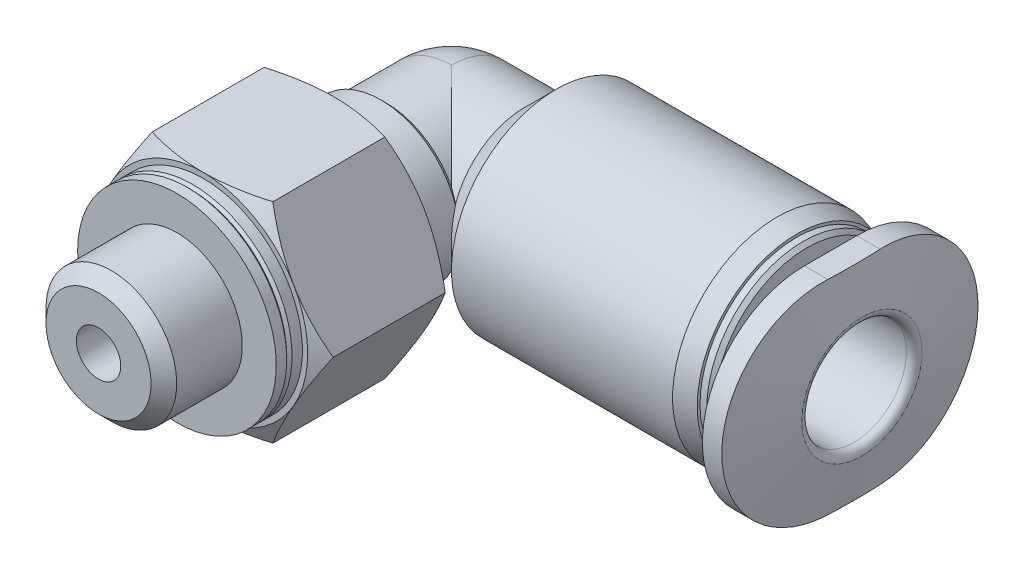
from build123d import *

# Parameters (mm, degrees)
CUT_EXTRUDE1_DEPTH = 1.2
SKETCH6_W          = 13.5
SKETCH6_H          = 0.85
SKETCH7_W          = 16
SKETCH7_H          = 16
CUT_EXTRUDE2_DEPTH = 6.055555556


with BuildPart() as part:
    # Sketch1 → Revolve1 (revolve)
    with BuildSketch(Plane.XY):
        with BuildLine():
            Line((0, 2.8), (2.8, 2.8))
            Line((2.8, 2.8), (4, 4))
            Line((4, 4), (12.457142857, 4))
            Line((12.457142857, 4), (13.2, 3.800952028))
            Line((13.2, 3.800952028), (13.2, 3.693772352))
            Line((13.2, 3.693772352), (13.458578644, 3.693772352))
            Line((13.458578644, 3.693772352), (13.6, 3.552350995))
            Line((13.6, 3.552350995), (13.6, 2.5))
            Line((13.6, 2.5), (14.13, 2.5))
            ThreePointArc((14.13, 2.5), (14.391629509, 2.608370491), (14.5, 2.87))
            Line((14.5, 2.87), (14.5, 5.9))
            Line((14.5, 5.9), (14.897402943, 5.9))
            ThreePointArc((14.897402943, 5.9), (15.025960465, 5.853208889), (15.094364494, 5.734729636))
            Line((15.094364494, 5.734729636), (15.7, 2.3))
            Line((15.7, 2.3), (15.7, 0))
            Line((15.7, 0), (-2.8, 0))
            ThreePointArc((-2.8, 0), (-1.979898987, 1.979898987), (0, 2.8))
        make_face()
    revolve(axis=Axis((15.7, 0, 0), (-1, 0, 0)))

    # Sketch2 → Revolve2 (revolve)
    with BuildSketch(Plane(origin=(0, 0, 0), x_dir=(0, 0, -1), z_dir=(1, 0, 0))):
        Polygon((-10.5, 0), (-10.5, 3.8), (-10.1, 3.8), (-10, 3.7), (-9.9, 3.8), (-9.5, 3.8), (-9.5, 4), (-9.130495828, 4.64), (-4.869504172, 4.64), (-4.5, 4), (-4.5, 3), (-2.7, 3), (-2.5, 2.8), (0, 2.8), (0, 0), align=None)
    revolve(axis=Axis((0, 0, 0), (0, 0, 1)))

    # Sketch3 → Revolve3 (revolve)
    with BuildSketch(Plane(origin=(0, 0, 0), x_dir=(0, 0, -1), z_dir=(1, 0, 0))):
        Polygon((-13.5, 0), (-13.5, 2.0095), (-13.0095, 2.5), (-10.5, 2.5), (-10.5, 0), align=None)
    revolve(axis=Axis((0, 0, 10.5), (0, 0, 1)))

    # Sketch4 → Cut-Extrude1 (cut)
    with BuildSketch(Plane(origin=(15.7, 0, 0), x_dir=(0, 0, -1), z_dir=(1, 0, 0))):
        Polygon((-9.8, -5.658032638), (0, -11.316065276), (9.8, -5.658032638), (9.8, 5.658032638), (0, 11.316065276), (-9.8, 5.658032638), align=None)
        with BuildLine():
            Line((-1, -3.9), (1, -3.9))
            ThreePointArc((1, -3.9), (4.9, 0), (1, 3.9))
            Line((1, 3.9), (-1, 3.9))
            ThreePointArc((-1, 3.9), (-4.9, 0), (-1, -3.9))
        make_face(mode=Mode.SUBTRACT)
    extrude(amount=-CUT_EXTRUDE1_DEPTH, mode=Mode.SUBTRACT)

    # Sketch6 → Cut-Revolve1 (revolve, cut)
    with BuildSketch(Plane(origin=(0, 0, 0), x_dir=(0, 0, -1), z_dir=(1, 0, 0))):
        with Locations((-6.75, 0.425)):
            Rectangle(SKETCH6_W, SKETCH6_H)
    revolve(axis=Axis((0, 0, 0), (0, 0, 1)), mode=Mode.SUBTRACT)

    # Sketch5 → Cut-Revolve2 (revolve, cut)
    with BuildSketch(Plane(origin=(0, 0, 0), x_dir=(1, 0, 0), z_dir=(0, 1, 0))):
        with BuildLine():
            Line((0, 0.85), (4.1, 0.85))
            Line((4.1, 0.85), (4.1, 2))
            Line((4.1, 2), (15.4, 2))
            ThreePointArc((15.4, 2), (15.612132034, 2.087867966), (15.7, 2.3))
            Line((15.7, 2.3), (15.7, 0))
            Line((15.7, 0), (-0.85, 0))
            ThreePointArc((-0.85, 0), (-0.601040764, 0.601040764), (0, 0.85))
        make_face()
    revolve(axis=Axis((15.7, 0, 0), (-1, 0, 0)), mode=Mode.SUBTRACT)

    # Sketch7 → Cut-Extrude2 (cut)
    with BuildSketch(Plane.XY.offset(10.5)):
        Rectangle(SKETCH7_W, SKETCH7_H)
        Polygon((-4.618802154, 0), (-2.309401077, -4), (2.309401077, -4), (4.618802154, 0), (2.309401077, 4), (-2.309401077, 4), align=None, mode=Mode.SUBTRACT)
    extrude(amount=-CUT_EXTRUDE2_DEPTH, mode=Mode.SUBTRACT)


solid = part.part
